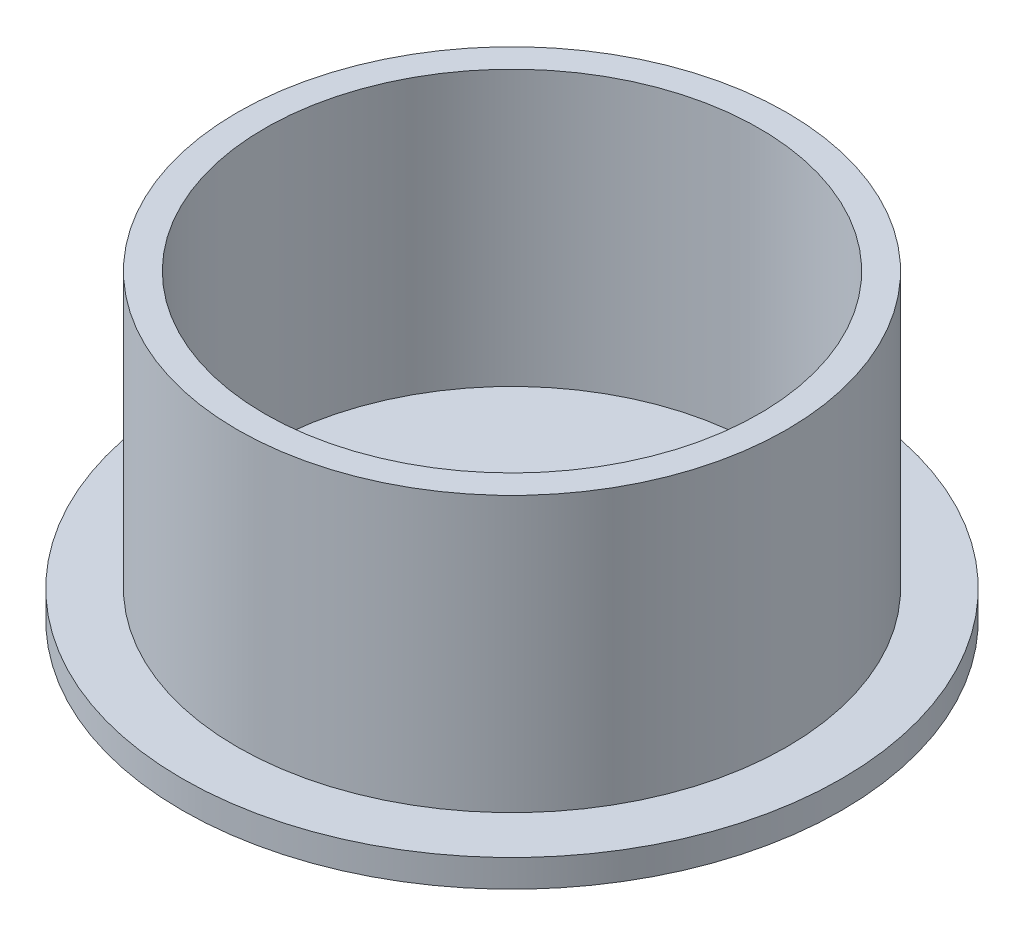
from build123d import *

# Parameters (mm, degrees)
SKETCH1_R           = 60
BOSS_EXTRUDE1_DEPTH = 5
SKETCH2_R           = 50
SKETCH2_R_2         = 45
BOSS_EXTRUDE2_DEPTH = 50


with BuildPart() as part:
    # Sketch1 → Boss-Extrude1 (new body)
    with BuildSketch(Plane(origin=(0, 0, 0), x_dir=(1, 0, 0), z_dir=(0, 1, 0))):
        Circle(SKETCH1_R)
    extrude(amount=BOSS_EXTRUDE1_DEPTH)

    # Sketch2 → Boss-Extrude2 (add)
    with BuildSketch(Plane(origin=(0, 5, 0), x_dir=(1, 0, 0), z_dir=(0, 1, 0))):
        Circle(SKETCH2_R)
        Circle(SKETCH2_R_2, mode=Mode.SUBTRACT)
    extrude(amount=BOSS_EXTRUDE2_DEPTH)


solid = part.part
